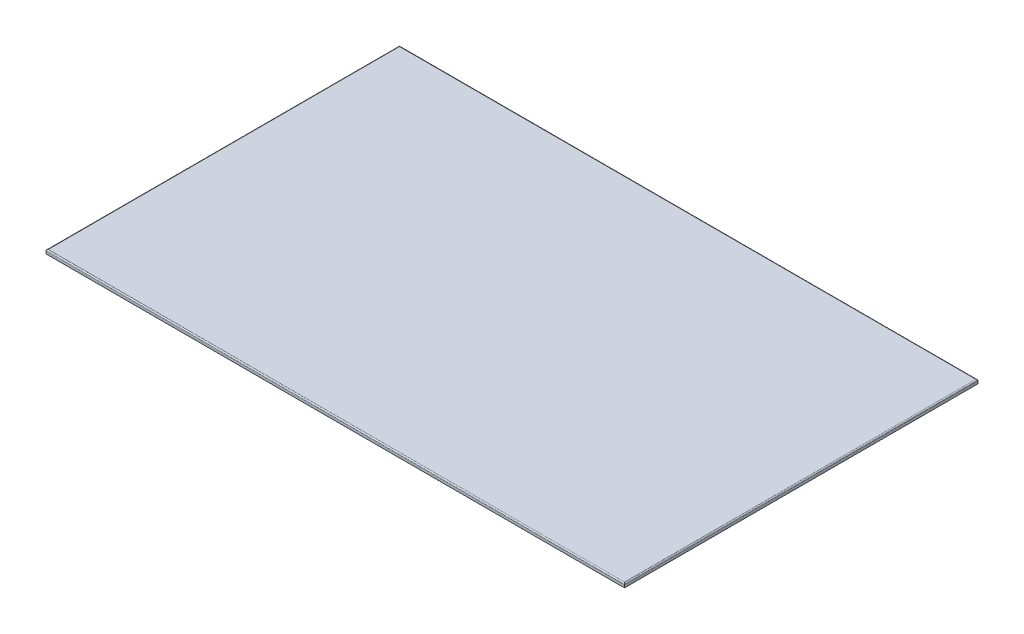
from build123d import *

# Parameters (mm, degrees)
SKETCH1_W           = 900
SKETCH1_H           = 550
BOSS_EXTRUDE1_DEPTH = 6
FILLET1_R           = 1.75


with BuildPart() as part:
    # Sketch1 → Boss-Extrude1 (new body)
    with BuildSketch(Plane(origin=(0, 0, 0), x_dir=(1, 0, 0), z_dir=(0, 1, 0))):
        Rectangle(SKETCH1_W, SKETCH1_H)
    extrude(amount=BOSS_EXTRUDE1_DEPTH)

    # Fillet1
    fillet1_edges = [part.edges().sort_by_distance(p)[0] for p in [
        (-450, 6, 0),
        (0, 6, 275),
        (450, 6, 0),
        (0, 6, -275),
    ]]
    fillet(fillet1_edges, radius=FILLET1_R)


solid = part.part
